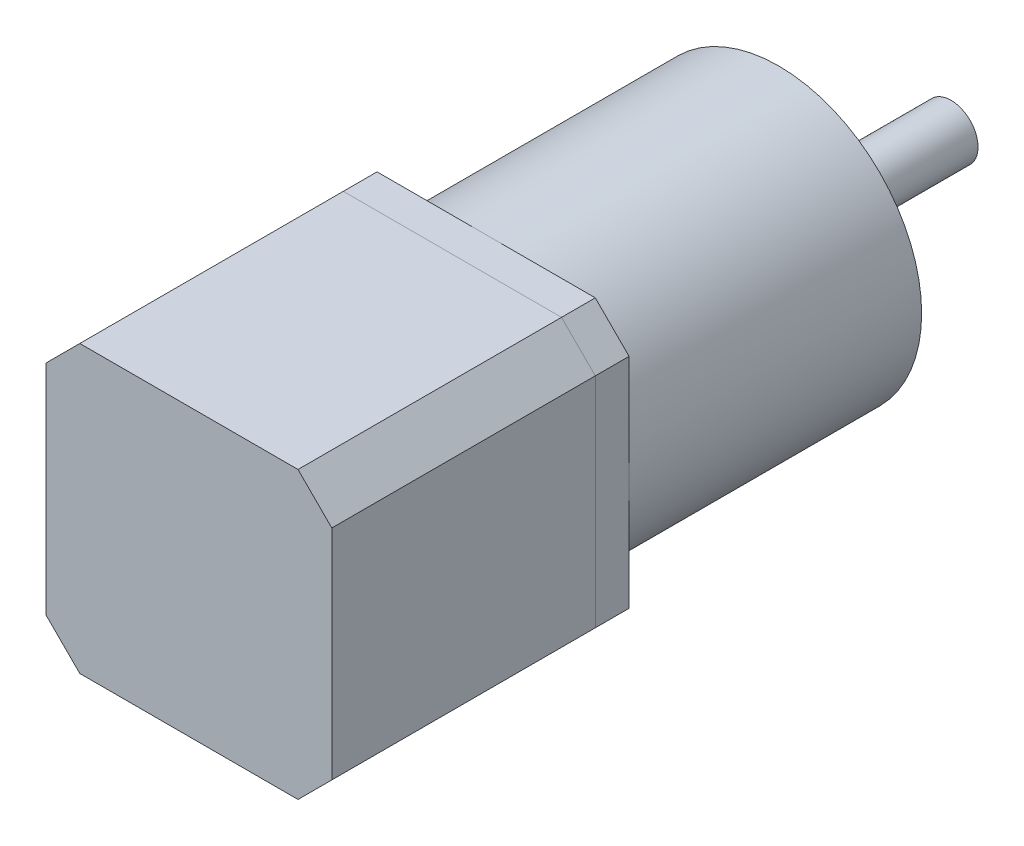
from build123d import *

# Parameters (mm, degrees)
SKETCH1_W           = 42.3
SKETCH1_H           = 42.3
BOSS_EXTRUDE1_DEPTH = 39
CHAMFER1_SIZE       = 5
SKETCH2_W           = 42.3
SKETCH2_H           = 42.3
BOSS_EXTRUDE2_DEPTH = 5
CHAMFER2_SIZE       = 5
SKETCH3_R           = 21.15
BOSS_EXTRUDE3_DEPTH = 43.3
SKETCH4_R           = 11
BOSS_EXTRUDE4_DEPTH = 2
SKETCH5_R           = 4
BOSS_EXTRUDE5_DEPTH = 23.5
SKETCH6_R           = 6.210975092
BOSS_EXTRUDE6_DEPTH = 0.5
SKETCH7_R           = 1.144150663
CUT_EXTRUDE1_DEPTH  = 10


with BuildPart() as part:
    # Sketch1 → Boss-Extrude1 (new body)
    with BuildSketch(Plane.XY):
        Rectangle(SKETCH1_W, SKETCH1_H)
    extrude(amount=BOSS_EXTRUDE1_DEPTH)

    # Chamfer1
    chamfer1_edges = [part.edges().sort_by_distance(p)[0] for p in [
        (21.15, -21.15, 19.5),
        (-21.15, -21.15, 19.5),
        (-21.15, 21.15, 19.5),
        (21.15, 21.15, 19.5),
    ]]
    chamfer(chamfer1_edges, length=CHAMFER1_SIZE)


with BuildPart() as body_2:
    # Sketch2 → Boss-Extrude2 (new body)
    with BuildSketch(Plane(origin=(0, 0, 0), x_dir=(-1, 0, 0), z_dir=(0, 0, -1))):
        Rectangle(SKETCH2_W, SKETCH2_H)
    extrude(amount=BOSS_EXTRUDE2_DEPTH)

    # Chamfer2
    chamfer2_edges = [body_2.edges().sort_by_distance(p)[0] for p in [
        (-21.15, -21.15, -2.5),
        (21.15, -21.15, -2.5),
        (21.15, 21.15, -2.5),
        (-21.15, 21.15, -2.5),
    ]]
    chamfer(chamfer2_edges, length=CHAMFER2_SIZE)


with BuildPart() as body_3:
    # Sketch3 → Boss-Extrude3 (new body)
    with BuildSketch(Plane(origin=(0, 0, -5), x_dir=(-1, 0, 0), z_dir=(0, 0, -1))):
        Circle(SKETCH3_R)
    extrude(amount=BOSS_EXTRUDE3_DEPTH)

    # Sketch7 → Cut-Extrude1 (cut)
    with BuildSketch(Plane(origin=(0, 0, -48.3), x_dir=(-1, 0, 0), z_dir=(0, 0, -1))):
        with Locations((0, 17.5)):
            Circle(SKETCH7_R)
        with Locations((17.5, 0)):
            Circle(SKETCH7_R)
        with Locations((0, -17.5)):
            Circle(SKETCH7_R)
        with Locations((-17.5, 0)):
            Circle(SKETCH7_R)
    extrude(amount=-CUT_EXTRUDE1_DEPTH, mode=Mode.SUBTRACT)


with BuildPart() as body_4:
    # Sketch4 → Boss-Extrude4 (new body)
    with BuildSketch(Plane(origin=(0, 0, -48.3), x_dir=(-1, 0, 0), z_dir=(0, 0, -1))):
        Circle(SKETCH4_R)
    extrude(amount=BOSS_EXTRUDE4_DEPTH)


with BuildPart() as body_5:
    # Sketch5 → Boss-Extrude5 (new body)
    with BuildSketch(Plane(origin=(0, 0, -50.3), x_dir=(-1, 0, 0), z_dir=(0, 0, -1))):
        Circle(SKETCH5_R)
    extrude(amount=BOSS_EXTRUDE5_DEPTH)


with BuildPart() as body_6:
    # Sketch6 → Boss-Extrude6 (new body)
    with BuildSketch(Plane(origin=(0, 0, -50.3), x_dir=(-1, 0, 0), z_dir=(0, 0, -1))):
        Circle(SKETCH6_R)
    extrude(amount=BOSS_EXTRUDE6_DEPTH)


solid = Compound([part.part, body_2.part, body_3.part, body_4.part, body_5.part, body_6.part])
